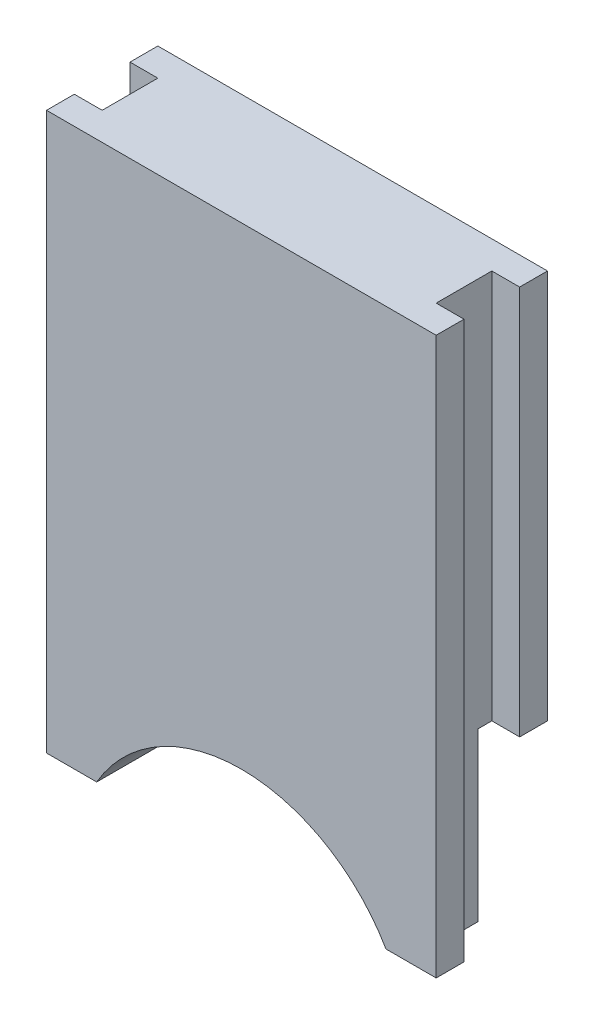
from build123d import *

# Parameters (mm, degrees)
EXTRUDE_1_DEPTH          = 4
SKETCH_2_W               = 1.5
SKETCH_2_H               = 6
CUT_EXTRUDE_1_DEPTH      = 15
SKETCH_3_W               = 1
SKETCH_3_H               = 2
CUT_EXTRUDE_2_DEPTH      = 1
CUT_EXTRUDE_2_DEPTH_BACK = 21


with BuildPart() as part:
    # 草图1 → 凸台-拉伸1 (new body)
    with BuildSketch(Plane.XY):
        with BuildLine():
            Line((-14, 20), (0, 20))
            Line((0, 20), (0, 0))
            Line((0, 0), (-1.803847577, 0))
            ThreePointArc((-1.803847577, 0), (-7, 3), (-12.196152423, 0))
            Line((-12.196152423, 0), (-14, 0))
            Line((-14, 0), (-14, 20))
        make_face()
    extrude(amount=EXTRUDE_1_DEPTH)

    # 草图2 → 切除-拉伸1 (cut, through all)
    with BuildSketch(Plane(origin=(0, 0, 0), x_dir=(0, 0, -1), z_dir=(1, 0, 0))):
        with Locations((-0.75, 3)):
            Rectangle(SKETCH_2_W, SKETCH_2_H)
    extrude(amount=-CUT_EXTRUDE_1_DEPTH, mode=Mode.SUBTRACT)

    # 草图3 → 切除-拉伸2 (cut, two sides)
    with BuildSketch(Plane(origin=(0, 20, 0), x_dir=(1, 0, 0), z_dir=(0, 1, 0))) as cut_extrude_2_sk:
        with Locations((-0.5, -2)):
            Rectangle(SKETCH_3_W, SKETCH_3_H)
        with Locations((-13.5, -2)):
            Rectangle(SKETCH_3_W, SKETCH_3_H)
    extrude(amount=CUT_EXTRUDE_2_DEPTH, mode=Mode.SUBTRACT)
    extrude(cut_extrude_2_sk.sketch, amount=-CUT_EXTRUDE_2_DEPTH_BACK, mode=Mode.SUBTRACT)


solid = part.part
